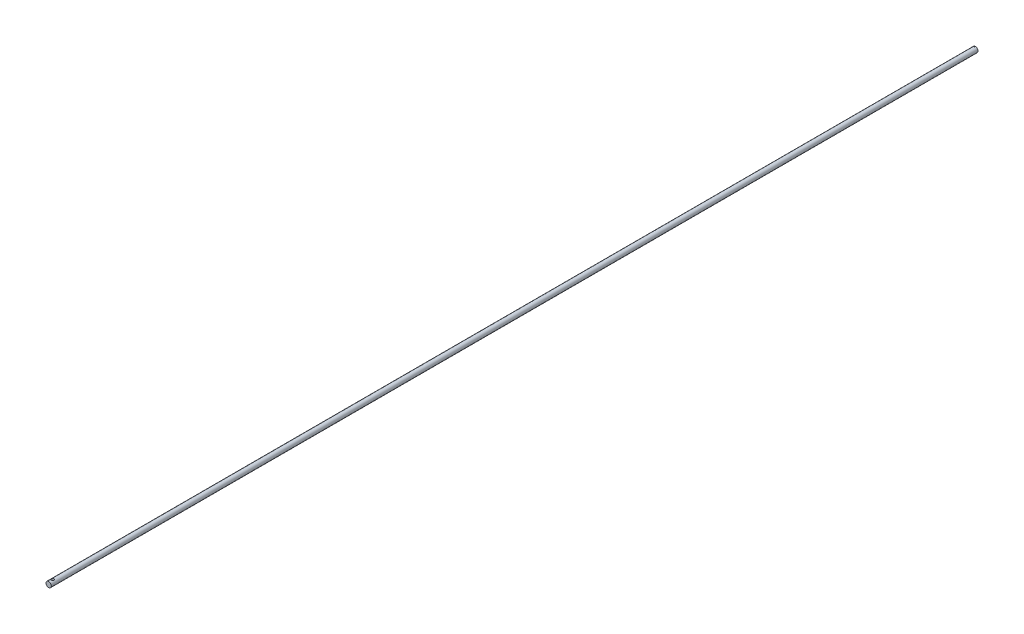
from build123d import *

# Parameters (mm, degrees)
SKETCH1_R               = 2.413
BOSS_EXTRUDE1_DEPTH     = 847.09
SKETCH2_R               = 1.27
SKETCH2_R_2             = 0.28089526
CUT_EXTRUDE1_DEPTH      = 3.413
CUT_EXTRUDE1_DEPTH_BACK = 3.413


with BuildPart() as part:
    # Sketch1 → Boss-Extrude1 (new body)
    with BuildSketch(Plane.XY):
        Circle(SKETCH1_R)
    extrude(amount=BOSS_EXTRUDE1_DEPTH)

    # Sketch2 → Cut-Extrude1 (cut, two sides)
    with BuildSketch(Plane(origin=(0, 0, 0), x_dir=(1, 0, 0), z_dir=(0, 1, 0))) as cut_extrude1_sk:
        with Locations((0, -843.555959397)):
            Circle(SKETCH2_R)
        with Locations((0, -0.735765283)):
            Circle(SKETCH2_R_2)
    extrude(amount=CUT_EXTRUDE1_DEPTH, mode=Mode.SUBTRACT)
    extrude(cut_extrude1_sk.sketch, amount=-CUT_EXTRUDE1_DEPTH_BACK, mode=Mode.SUBTRACT)


solid = part.part
